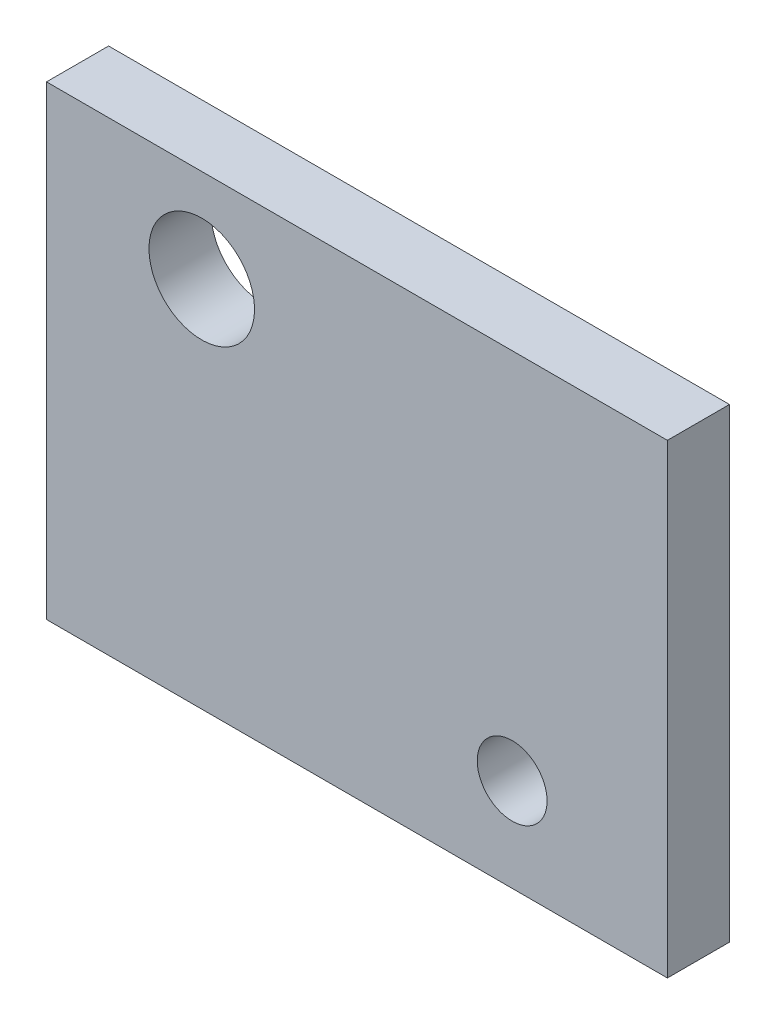
from build123d import *

# Parameters (mm, degrees)
SKETCH1_W           = 200
SKETCH1_H           = 150
BOSS_EXTRUDE1_DEPTH = 20
SKETCH2_R           = 11.25
SKETCH2_R_2         = 17
CUT_EXTRUDE1_DEPTH  = 21


with BuildPart() as part:
    # Sketch1 → Boss-Extrude1 (new body)
    with BuildSketch(Plane.XY):
        Rectangle(SKETCH1_W, SKETCH1_H)
    extrude(amount=BOSS_EXTRUDE1_DEPTH)

    # Sketch2 → Cut-Extrude1 (cut, through all)
    with BuildSketch(Plane(origin=(0, 0, 0), x_dir=(-1, 0, 0), z_dir=(0, 0, -1))):
        with Locations((-50, -45)):
            Circle(SKETCH2_R)
        with Locations((50, 45)):
            Circle(SKETCH2_R_2)
    extrude(amount=-CUT_EXTRUDE1_DEPTH, mode=Mode.SUBTRACT)


solid = part.part
